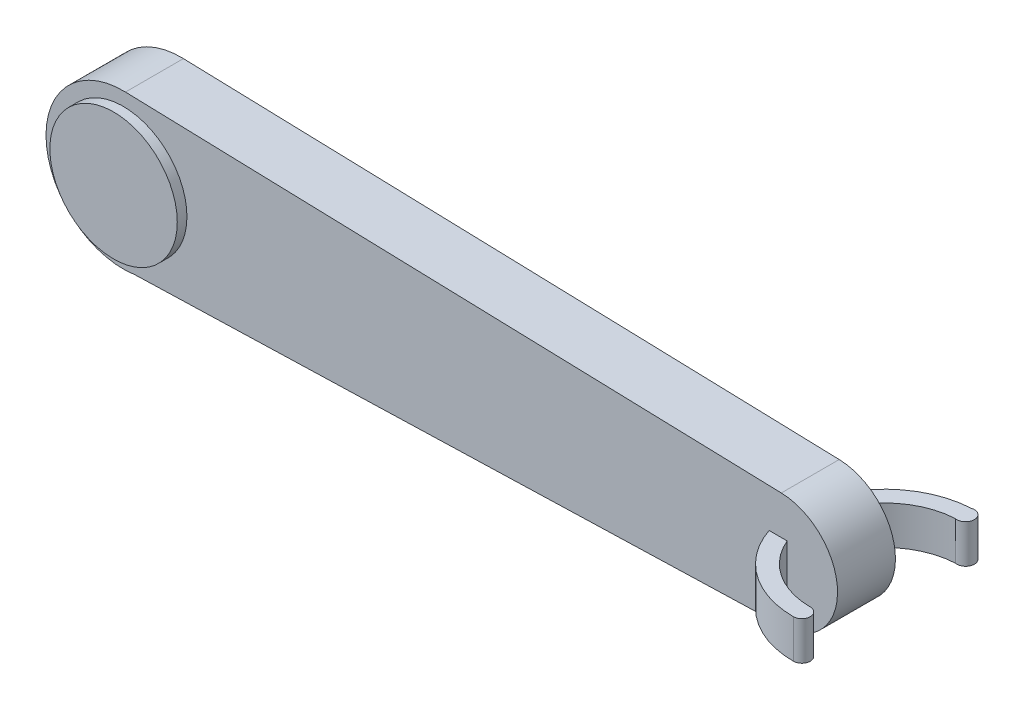
from build123d import *

# Parameters (mm, degrees)
BOSS_EXTRUDE1_DEPTH = 7.5
SKETCH3_R           = 16.5
BOSS_EXTRUDE2_DEPTH = 2.5
SKETCH7_R           = 5
BOSS_EXTRUDE3_DEPTH = 10
BOSS_EXTRUDE4_DEPTH = 5


with BuildPart() as part:
    # Sketch1 → Boss-Extrude1 (new body, symmetric)
    with BuildSketch(Plane.XY):
        with BuildLine():
            Line((-81.983854392, -19.771263634), (88.350129521, -14.621102291))
            ThreePointArc((88.350129521, -14.621102291), (99.92815548, 1.466347152), (85.441176471, 14.993510707))
            Line((85.441176471, 14.993510707), (-84.411764706, 19.991347609))
            ThreePointArc((-84.411764706, 19.991347609), (-104.962820533, -1.218932468), (-81.983854392, -19.771263634))
        make_face()
    extrude(amount=BOSS_EXTRUDE1_DEPTH, both=True)

    # Sketch3 → Boss-Extrude2 (add, symmetric)
    with BuildSketch(Plane.XY.offset(7.5)):
        with Locations((-85, 0)):
            Circle(SKETCH3_R)
    extrude(amount=BOSS_EXTRUDE2_DEPTH, both=True)

    # Sketch7 → Boss-Extrude3 (add)
    with BuildSketch(Plane(origin=(0, 0, -7.5), x_dir=(-1, 0, 0), z_dir=(0, 0, -1))):
        with Locations((85, 0)):
            Circle(SKETCH7_R)
    extrude(amount=BOSS_EXTRUDE3_DEPTH)

    # Sketch12 → Boss-Extrude4 (add, symmetric)
    with BuildSketch(Plane(origin=(0, 0, 0), x_dir=(1, 0, 0), z_dir=(0, 1, 0))):
        with BuildLine():
            ThreePointArc((103.475564721, 23.657260108), (81.077385627, -0.642858818), (104.760808967, -23.692146559))
            ThreePointArc((104.760808967, -23.692146559), (106.947065998, -21.505889528), (104.760808967, -19.319632497))
            ThreePointArc((104.760808967, -19.319632497), (85.448289772, -0.524215738), (103.712763513, 19.291184529))
            ThreePointArc((103.712763513, 19.291184529), (106.436573923, 21.628643871), (103.475564721, 23.657260108))
        make_face()
    extrude(amount=BOSS_EXTRUDE4_DEPTH, both=True)


solid = part.part
